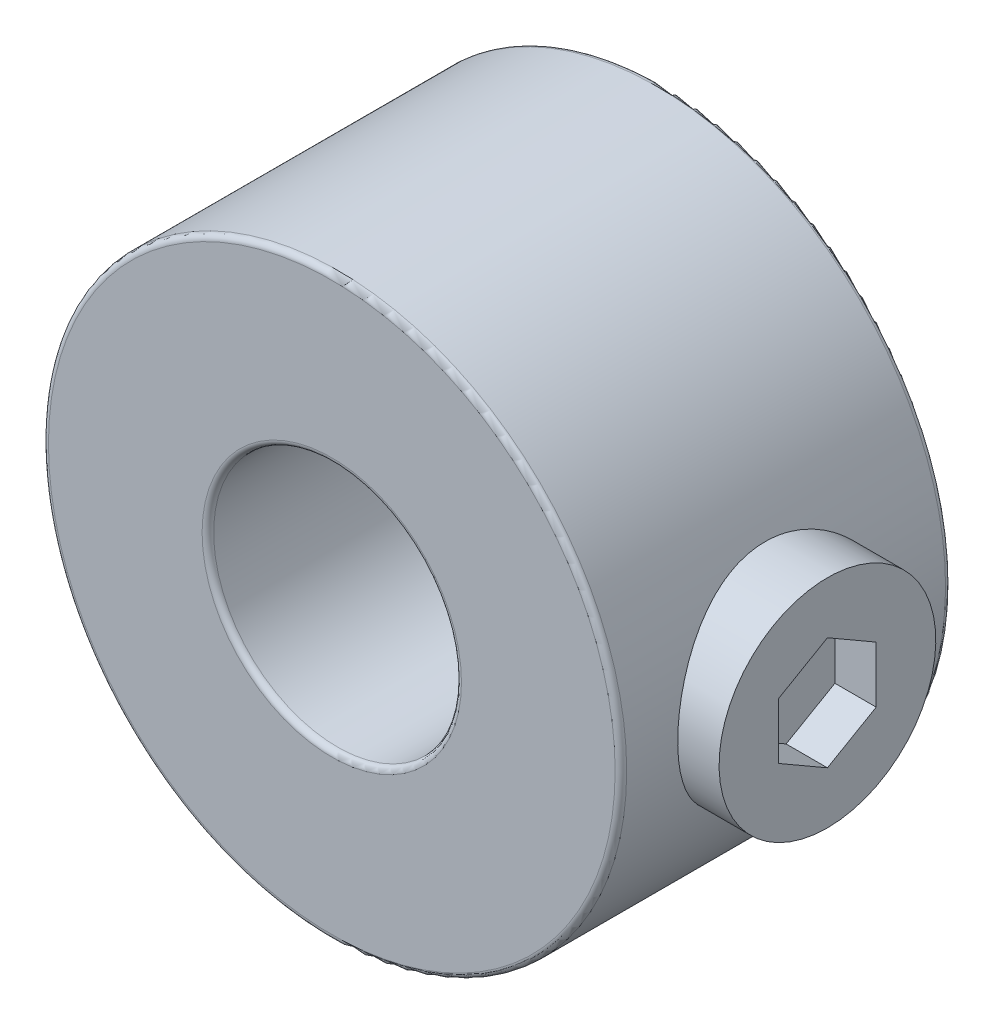
from build123d import *

# Parameters (mm, degrees)
SKETCH1_R          = 5.55625
SKETCH1_R_2        = 2.38125
EXTRUDE1_DEPTH     = 6.35
CUT_EXTRUDE1_REACH = 13.112
SKETCH2_R          = 2.0828
SKETCH3_W          = 3.175
SKETCH3_H          = 2.0828
CUT_EXTRUDE2_DEPTH = 0.79375
FILLET1_R          = 0.111125


with BuildPart() as part:
    # Sketch1 → Extrude1 (new body)
    with BuildSketch(Plane.XY):
        Circle(SKETCH1_R)
        Circle(SKETCH1_R_2, mode=Mode.SUBTRACT)
    extrude(amount=EXTRUDE1_DEPTH)

    # Sketch2 → Cut-Extrude1 (cut, up to next)
    with BuildSketch(Plane(origin=(5.55625, 0, 0), x_dir=(0, 0, -1), z_dir=(1, 0, 0)), mode=Mode.PRIVATE) as cut_extrude1_sk1:
        with Locations((-3.175, 0)):
            Circle(SKETCH2_R)
    cut_extrude1_tool1 = extrude(cut_extrude1_sk1.sketch, amount=-CUT_EXTRUDE1_REACH, mode=Mode.PRIVATE) & part.part
    add(cut_extrude1_tool1.solids().sort_by_distance((5.55625, 0, 3.175))[0], mode=Mode.SUBTRACT)

    # Fillet1
    fillet1_edges = [part.edges().sort_by_distance(p)[0] for p in [
        (-5.55625, 0, 0),
        (-5.55625, 0, 6.35),
        (-2.38125, 0, 0),
        (-2.38125, 0, 6.35),
    ]]
    fillet(fillet1_edges, radius=FILLET1_R)


with BuildPart() as body_2:
    # Sketch3 → Revolve1 (revolve)
    with BuildSketch(Plane.XY.offset(3.175)):
        with Locations((4.7625, 1.0414)):
            Rectangle(SKETCH3_W, SKETCH3_H)
    revolve(axis=Axis((3.175, 0, 3.175), (1, 0, 0)))

    # Sketch4 → Cut-Extrude2 (cut)
    with BuildSketch(Plane(origin=(6.35, 0, 0), x_dir=(0, 0, -1), z_dir=(1, 0, 0))):
        Polygon((-3.175, 1.082254627), (-4.11226, 0.541127313), (-4.11226, -0.541127313), (-3.175, -1.082254627), (-2.23774, -0.541127313), (-2.23774, 0.541127313), align=None)
    extrude(amount=-CUT_EXTRUDE2_DEPTH, mode=Mode.SUBTRACT)


solid = Compound([part.part, body_2.part])
